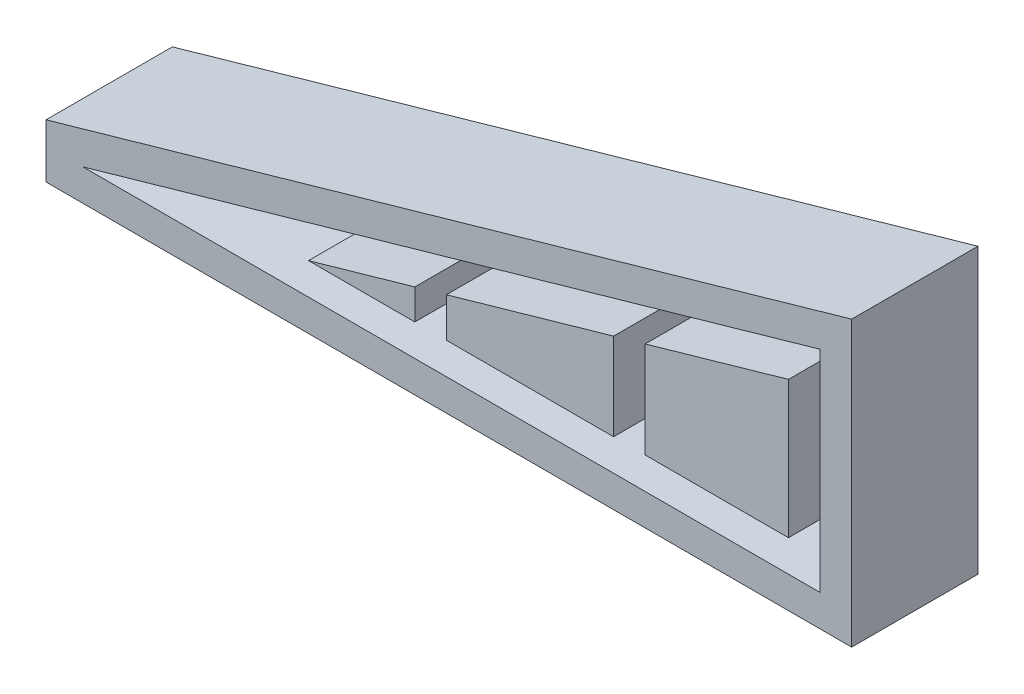
from build123d import *

# Parameters (mm, degrees)
BOSS_EXTRUDE1_DEPTH   = 10
BOSS_EXTRUDE1_2_DEPTH = 10
BOSS_EXTRUDE1_3_DEPTH = 10
BOSS_EXTRUDE1_4_DEPTH = 10
BOSS_EXTRUDE2_DEPTH   = 2


with BuildPart() as part:
    # Sketch1 → Boss-Extrude1 (new body)
    with BuildSketch(Plane.XY):
        Polygon((-45.029672623, -17.414149003), (-45.029672623, -12.296865077), (31.479998469, 9.563040949), (31.479998469, -17.414149003), align=None)
        Polygon((28.479998469, -14.414149003), (-41.520001531, -14.414149003), (28.479998469, 5.585850997), align=None, mode=Mode.SUBTRACT)
    extrude(amount=BOSS_EXTRUDE1_DEPTH)



with BuildPart() as body_2:
    # Sketch1 → Boss-Extrude1 2 (new body)
    with BuildSketch(Plane.XY):
        Polygon((-20.099836697, -11.414149003), (-10.005608589, -8.530083829), (-10.005608589, -11.414149003), align=None)
    extrude(amount=BOSS_EXTRUDE1_2_DEPTH)


with BuildPart() as body_3:
    # Sketch1 → Boss-Extrude1 3 (new body)
    with BuildSketch(Plane.XY):
        Polygon((-7.005608589, -7.672940972), (8.872659236, -3.136293022), (8.872659236, -11.414149003), (-7.005608589, -11.414149003), align=None)
    extrude(amount=BOSS_EXTRUDE1_3_DEPTH)


with BuildPart() as body_4:
    # Sketch1 → Boss-Extrude1 4 (new body)
    with BuildSketch(Plane.XY):
        Polygon((11.872659236, -2.279150165), (25.479998469, 1.608661044), (25.479998469, -11.414149003), (11.872659236, -11.414149003), align=None)
    extrude(amount=BOSS_EXTRUDE1_4_DEPTH)


with BuildPart() as part_1:
    add(part.part)

    add(body_2.part)  # Boss-Extrude2 merges body 2

    add(body_3.part)  # Boss-Extrude2 merges body 3

    add(body_4.part)  # Boss-Extrude2 merges body 4
    # Sketch2 → Boss-Extrude2 (add)
    with BuildSketch(Plane(origin=(0, 0, 0), x_dir=(-1, 0, 0), z_dir=(0, 0, -1))):
        Polygon((-31.479998469, 9.563040949), (45.029672623, -12.296865077), (45.029672623, -17.414149003), (-31.479998469, -17.414149003), align=None)
    extrude(amount=BOSS_EXTRUDE2_DEPTH)


solid = part_1.part
